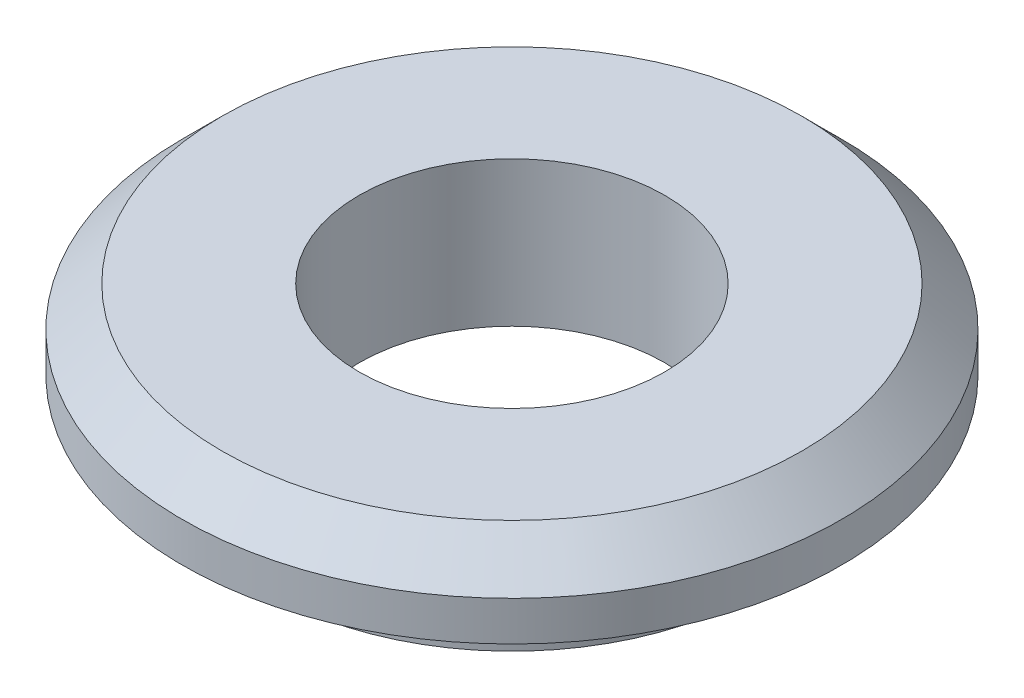
from build123d import *


with BuildPart() as part:
    # Sketch1 → Revolve1 (revolve)
    with BuildSketch(Plane.XY):
        Polygon((-1.4732, 0), (-1.4732, -1.397), (-2.3622, -1.397), (-2.3622, -0.762), (-3.175, -0.762), (-3.175, -0.381), (-2.794, 0), align=None)
    revolve(axis=Axis((0, 0, 0), (0, -1, 0)))


solid = part.part
